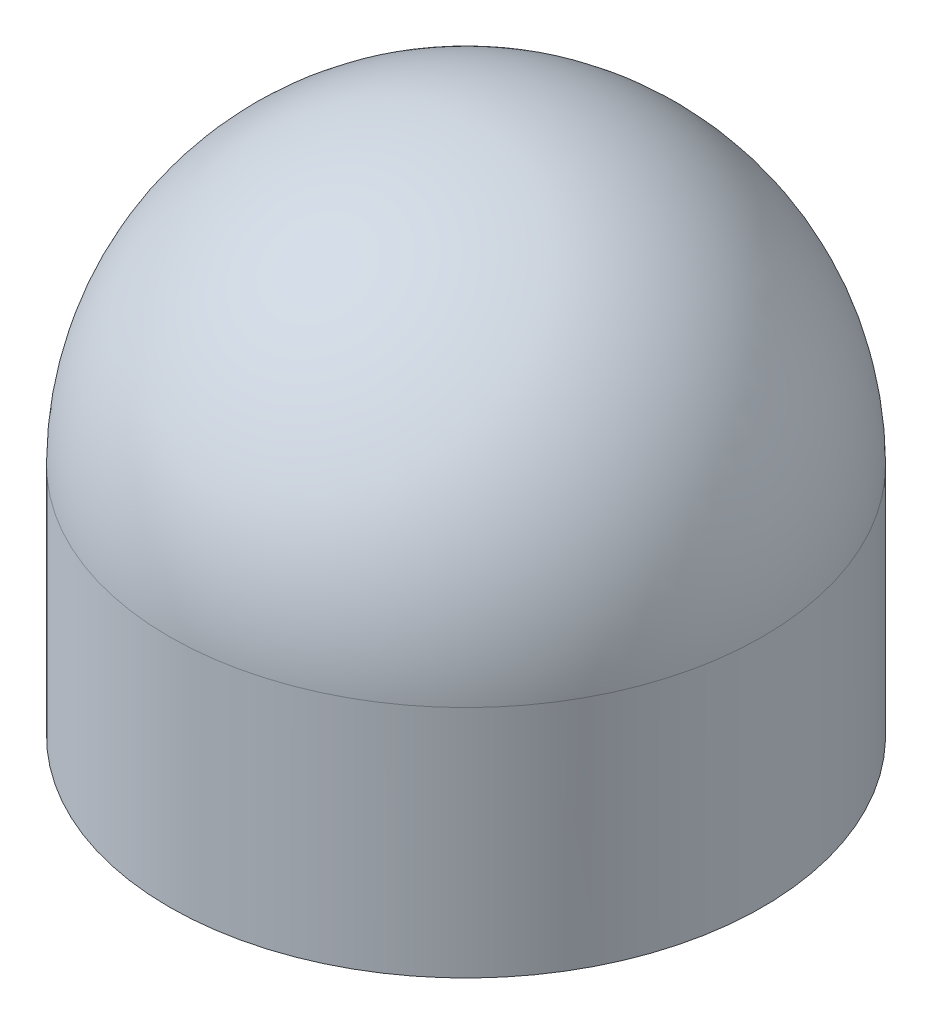
from build123d import *


with BuildPart() as part:
    # Çizim1 → Döndür1 (revolve)
    with BuildSketch(Plane.XY):
        with BuildLine():
            Line((0, 17.272), (0, 7.62))
            Line((0, 7.62), (0, 0))
            Line((0, 0), (9.652, 0))
            Line((9.652, 0), (9.652, 7.62))
            ThreePointArc((9.652, 7.62), (6.824994652, 14.444994652), (0, 17.272))
        make_face()
    revolve(axis=Axis((0, 17.272, 0), (0, -1, 0)))


solid = part.part
